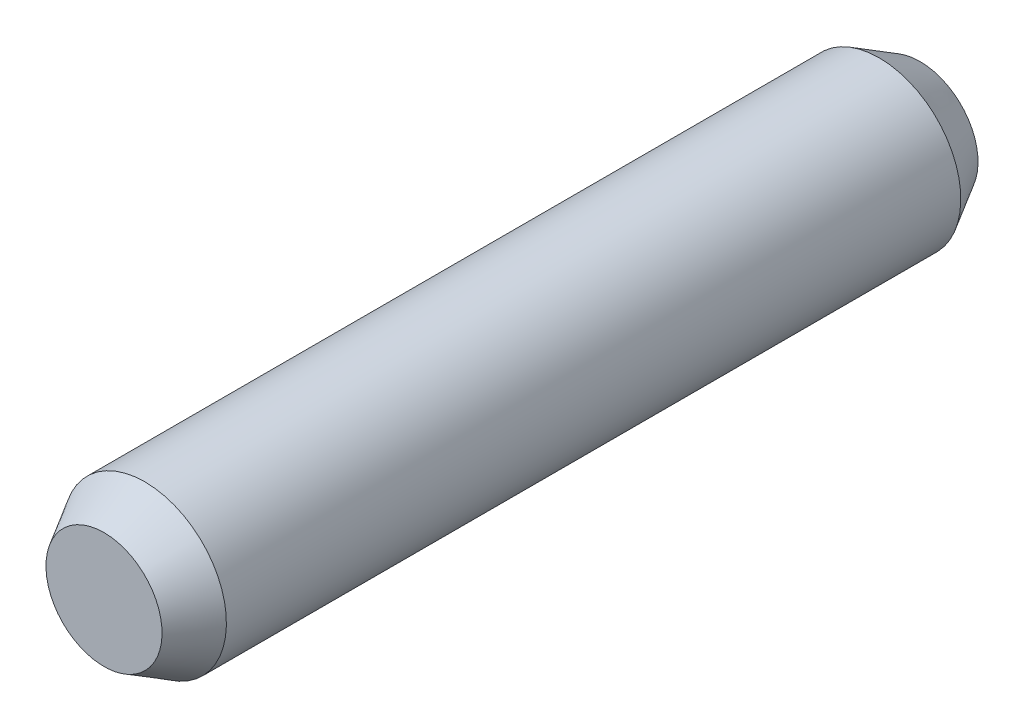
from build123d import *


with BuildPart() as part:
    # Skizze1 → Rotation1 (revolve)
    with BuildSketch(Plane(origin=(0, 0, 0), x_dir=(0, 0, -1), z_dir=(1, 0, 0))):
        Polygon((-27, 6), (27, 6), (30, 4.267949192), (30, 0), (-30, 0), (-30, 4.267949192), align=None)
    revolve(axis=Axis((0, 0, -30), (0, 0, 1)))


solid = part.part
